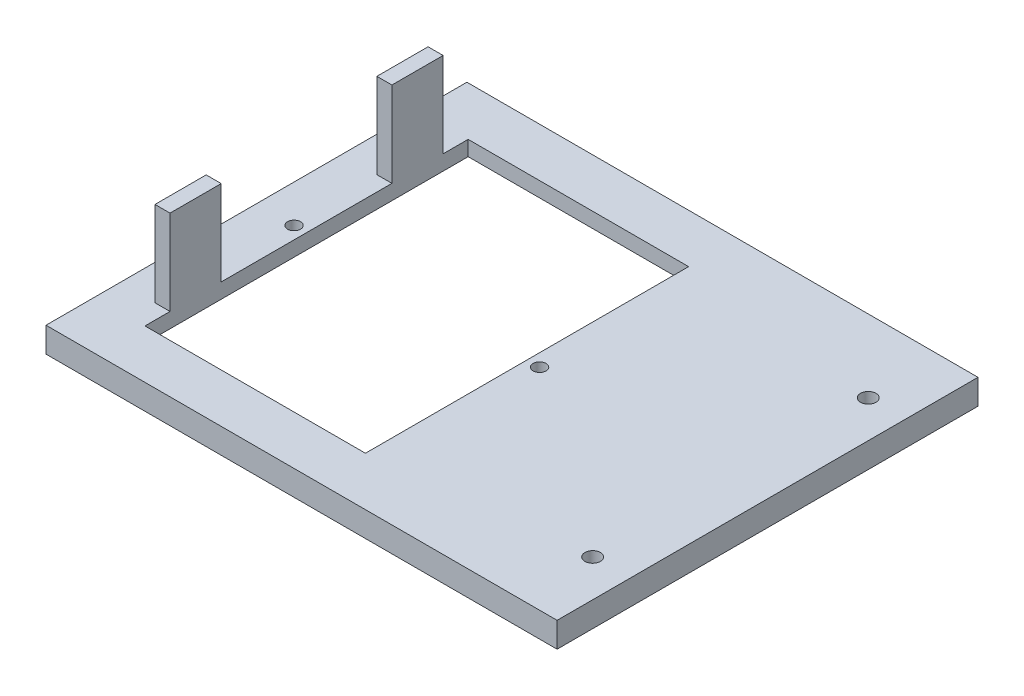
from build123d import *

# Parameters (mm, degrees)
SKETCH1_W           = 110
SKETCH1_H           = 84
BOSS_EXTRUDE1_DEPTH = 5
SKETCH2_W           = 44
SKETCH2_H           = 64.5
CUT_EXTRUDE1_DEPTH  = 5
SKETCH3_R           = 1.55
CUT_EXTRUDE2_DEPTH  = 5
SKETCH5_W           = 3
SKETCH5_H           = 10.213632632
BOSS_EXTRUDE2_DEPTH = 17
SKETCH6_W           = 54
SKETCH6_H           = 74.5
CUT_EXTRUDE3_DEPTH  = 2
CUT_EXTRUDE4_REACH  = 22
SKETCH7_R           = 1.3
SKETCH8_W           = 84
SKETCH8_H           = 5
CUT_EXTRUDE5_DEPTH  = 8


with BuildPart() as part:
    # Sketch1 → Boss-Extrude1 (new body)
    with BuildSketch(Plane(origin=(0, 0, 0), x_dir=(1, 0, 0), z_dir=(0, 1, 0))):
        Rectangle(SKETCH1_W, SKETCH1_H)
    extrude(amount=BOSS_EXTRUDE1_DEPTH)

    # Sketch2 → Cut-Extrude1 (cut)
    with BuildSketch(Plane(origin=(0, 5, 0), x_dir=(1, 0, 0), z_dir=(0, 1, 0))):
        with Locations((-23, 0)):
            Rectangle(SKETCH2_W, SKETCH2_H)
    extrude(amount=-CUT_EXTRUDE1_DEPTH, mode=Mode.SUBTRACT)

    # Sketch3 → Cut-Extrude2 (cut)
    with BuildSketch(Plane(origin=(0, 5, 0), x_dir=(1, 0, 0), z_dir=(0, 1, 0))):
        with Locations((39.6, 27.5)):
            Circle(SKETCH3_R)
        with Locations((39.6, -27.5)):
            Circle(SKETCH3_R)
    extrude(amount=-CUT_EXTRUDE2_DEPTH, mode=Mode.SUBTRACT)

    # Sketch5 → Boss-Extrude2 (add)
    with BuildSketch(Plane(origin=(0, 5, 0), x_dir=(1, 0, 0), z_dir=(0, 1, 0))):
        with Locations((-46.5, 22.143183684)):
            Rectangle(SKETCH5_W, SKETCH5_H)
        with Locations((-46.5, -22.143183684)):
            Rectangle(SKETCH5_W, SKETCH5_H)
    extrude(amount=BOSS_EXTRUDE2_DEPTH)

    # Sketch6 → Cut-Extrude3 (cut)
    with BuildSketch(Plane.XZ):
        with Locations((-23, 0)):
            Rectangle(SKETCH6_W, SKETCH6_H)
    extrude(amount=-CUT_EXTRUDE3_DEPTH, mode=Mode.SUBTRACT)

    # Sketch7 → Cut-Extrude4 (cut, up to next)
    with BuildSketch(Plane.XZ.offset(-2), mode=Mode.PRIVATE) as cut_extrude4_sk1:
        with Locations((-47.5, 0)):
            Circle(SKETCH7_R)
    cut_extrude4_tool1 = extrude(cut_extrude4_sk1.sketch, amount=-CUT_EXTRUDE4_REACH, mode=Mode.PRIVATE) & part.part
    add(cut_extrude4_tool1.solids().sort_by_distance((-47.5, 2, 0))[0], mode=Mode.SUBTRACT)
    # Sketch7 → Cut-Extrude4 (cut, up to next)
    with BuildSketch(Plane.XZ.offset(-2), mode=Mode.PRIVATE) as cut_extrude4_sk2:
        with Locations((1.5, 0)):
            Circle(SKETCH7_R)
    cut_extrude4_tool2 = extrude(cut_extrude4_sk2.sketch, amount=-CUT_EXTRUDE4_REACH, mode=Mode.PRIVATE) & part.part
    add(cut_extrude4_tool2.solids().sort_by_distance((1.5, 2, 0))[0], mode=Mode.SUBTRACT)

    # Sketch8 → Cut-Extrude5 (cut)
    with BuildSketch(Plane(origin=(55, 0, 0), x_dir=(0, 0, -1), z_dir=(1, 0, 0))):
        with Locations((0, 2.5)):
            Rectangle(SKETCH8_W, SKETCH8_H)
    extrude(amount=-CUT_EXTRUDE5_DEPTH, mode=Mode.SUBTRACT)


solid = part.part
